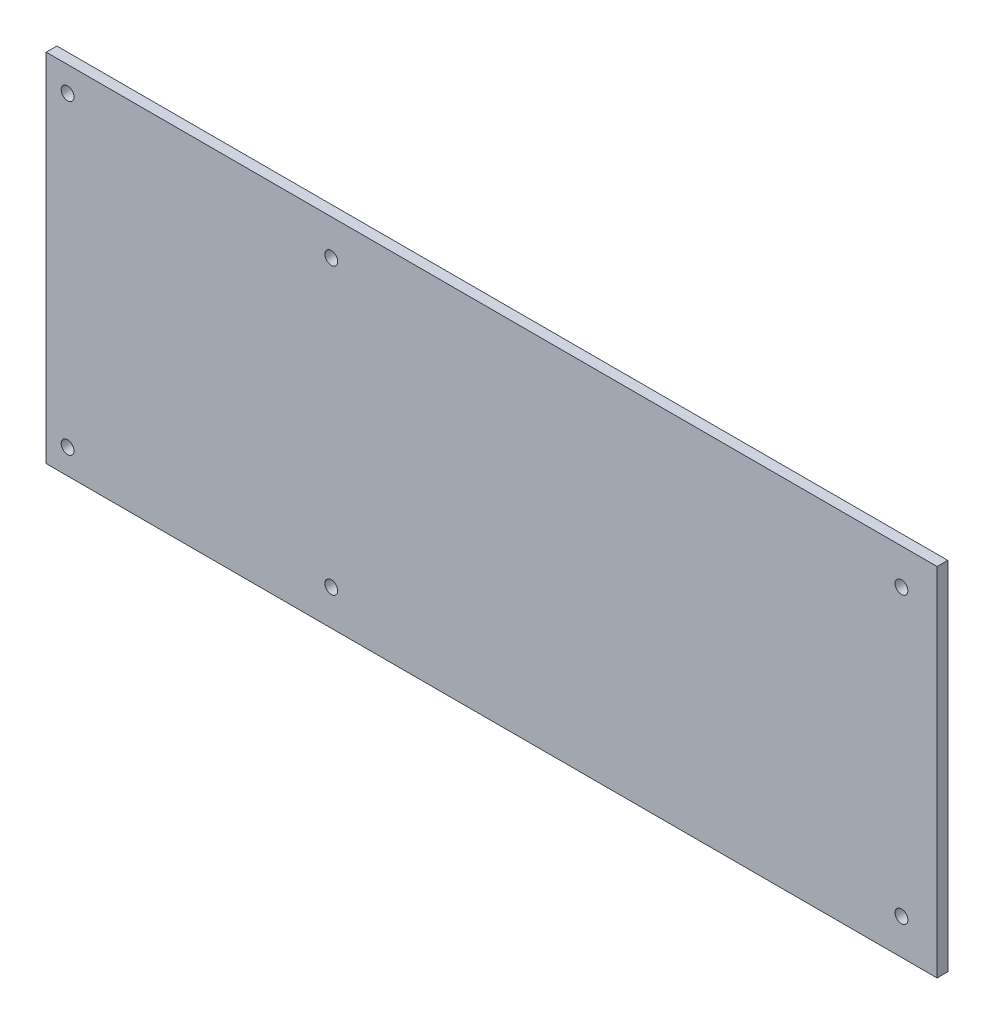
from build123d import *

# Parameters (mm, degrees)
SKETCH1_W           = 250
SKETCH1_H           = 100
BOSS_EXTRUDE1_DEPTH = 3
SKETCH2_R           = 1.8
CUT_EXTRUDE1_DEPTH  = 4


with BuildPart() as part:
    # Sketch1 → Boss-Extrude1 (new body)
    with BuildSketch(Plane.XY):
        with Locations((125, 50)):
            Rectangle(SKETCH1_W, SKETCH1_H)
    extrude(amount=BOSS_EXTRUDE1_DEPTH)

    # Sketch2 → Cut-Extrude1 (cut, through all)
    with BuildSketch(Plane.XY.offset(3)):
        with Locations((6, 93)):
            Circle(SKETCH2_R)
        with Locations((80, 90)):
            Circle(SKETCH2_R)
        with Locations((240, 90)):
            Circle(SKETCH2_R)
        with Locations((240, 10)):
            Circle(SKETCH2_R)
        with Locations((80, 10)):
            Circle(SKETCH2_R)
        with Locations((6, 7)):
            Circle(SKETCH2_R)
    extrude(amount=-CUT_EXTRUDE1_DEPTH, mode=Mode.SUBTRACT)


solid = part.part
